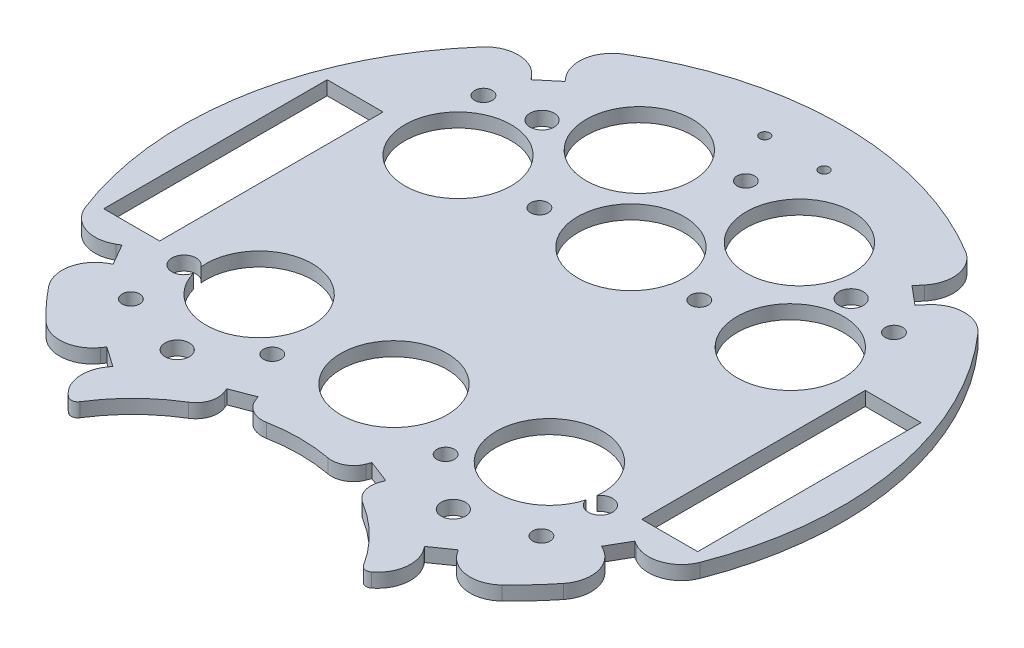
from build123d import *

# Parameters (mm, degrees)
SKETCH1_R           = 2
SKETCH1_R_2         = 2.75
SKETCH1_W           = 12.7
SKETCH1_H           = 50.8
SKETCH1_R_3         = 12.095
SKETCH1_R_4         = 12.075
SKETCH1_R_5         = 1.143
BOSS_EXTRUDE1_DEPTH = 3.175


with BuildPart() as part:
    # Sketch1 → Boss-Extrude1 (new body)
    with BuildSketch(Plane(origin=(0, 0, 0), x_dir=(1, 0, 0), z_dir=(0, 1, 0))):
        with BuildLine():
            Line((-35.441180971, -55.409730648), (-36.014757408, -56.228882693))
            ThreePointArc((-36.014757408, -56.228882693), (-37.282182463, -61.682274385), (-34.419720881, -66.493943628))
            ThreePointArc((-34.419720881, -66.493943628), (-33.243515234, -66.777434912), (-32.240681933, -66.10056535))
            ThreePointArc((-32.240681933, -66.10056535), (-26.728650164, -59.250774979), (-19.793246149, -53.846860332))
            ThreePointArc((-19.793246149, -53.846860332), (-17.659799789, -51.192486841), (-17.721018114, -47.787557426))
            Line((-17.721018114, -47.787557426), (-18.078412971, -46.853604046))
            Line((-18.078412971, -46.853604046), (-12.941669381, -44.887932332))
            Line((-12.941669381, -44.887932332), (-12.584274523, -45.821885712))
            ThreePointArc((-12.584274523, -45.821885712), (-10.356790186, -48.397852623), (-6.996351286, -48.949887413))
            ThreePointArc((-6.996351286, -48.949887413), (0, -48.302004425), (6.996351286, -48.949887413))
            ThreePointArc((6.996351286, -48.949887413), (10.356790186, -48.397852623), (12.584274523, -45.821885712))
            Line((12.584274523, -45.821885712), (12.941669381, -44.887932332))
            Line((12.941669381, -44.887932332), (18.078412971, -46.853604046))
            Line((18.078412971, -46.853604046), (17.721018114, -47.787557426))
            ThreePointArc((17.721018114, -47.787557426), (17.659799789, -51.192486841), (19.793246149, -53.846860332))
            ThreePointArc((19.793246149, -53.846860332), (26.728650164, -59.250774979), (32.240681933, -66.10056535))
            ThreePointArc((32.240681933, -66.10056535), (33.243515234, -66.777434912), (34.419720881, -66.493943628))
            ThreePointArc((34.419720881, -66.493943628), (37.282182463, -61.682274385), (36.014757408, -56.228882693))
            Line((36.014757408, -56.228882693), (35.441180971, -55.409730648))
            Line((35.441180971, -55.409730648), (39.946517215, -52.255060248))
            Line((39.946517215, -52.255060248), (40.520093651, -53.074212293))
            ThreePointArc((40.520093651, -53.074212293), (45.927580176, -56.23617342), (51.848593315, -54.191543356))
            ThreePointArc((51.848593315, -54.191543356), (55.295899374, -50.669157408), (58.504414423, -46.927960674))
            ThreePointArc((58.504414423, -46.927960674), (60.025192689, -40.851285995), (56.403972981, -35.739974078))
            Line((56.403972981, -35.739974078), (55.537947577, -35.239974078))
            Line((55.537947577, -35.239974078), (58.287686569, -30.477286437))
            Line((58.287686569, -30.477286437), (59.153711973, -30.977286437))
            ThreePointArc((59.153711973, -30.977286437), (65.390847794, -31.557698738), (69.893013303, -27.202328787))
            ThreePointArc((69.893013303, -27.202328787), (73.860606951, 13.023468848), (56.374397975, 49.466425512))
            ThreePointArc((56.374397975, 49.466425512), (50.654117331, 52.01932544), (44.991624855, 49.340690033))
            Line((44.991624855, 49.340690033), (43.706049635, 47.808601147))
            Line((43.706049635, 47.808601147), (39.492805198, 51.343933))
            Line((39.492805198, 51.343933), (40.778380417, 52.876021886))
            ThreePointArc((40.778380417, 52.876021886), (42.433039833, 58.917628536), (38.925607882, 64.107698843))
            ThreePointArc((38.925607882, 64.107698843), (0, 75), (-38.925607882, 64.107698843))
            ThreePointArc((-38.925607882, 64.107698843), (-42.433039833, 58.917628536), (-40.778380417, 52.876021886))
            Line((-40.778380417, 52.876021886), (-40.135592808, 52.109977443))
            Line((-40.135592808, 52.109977443), (-44.348837245, 48.57464559))
            Line((-44.348837245, 48.57464559), (-44.991624855, 49.340690033))
            ThreePointArc((-44.991624855, 49.340690033), (-50.654117331, 52.01932544), (-56.374397975, 49.466425512))
            ThreePointArc((-56.374397975, 49.466425512), (-73.860606951, 13.023468848), (-69.893013303, -27.202328787))
            ThreePointArc((-69.893013303, -27.202328787), (-65.390847794, -31.557698738), (-59.153711973, -30.977286437))
            Line((-59.153711973, -30.977286437), (-58.287686569, -30.477286437))
            Line((-58.287686569, -30.477286437), (-55.537947577, -35.239974078))
            Line((-55.537947577, -35.239974078), (-56.403972981, -35.739974078))
            ThreePointArc((-56.403972981, -35.739974078), (-60.025192689, -40.851285995), (-58.504414423, -46.927960674))
            ThreePointArc((-58.504414423, -46.927960674), (-55.295899374, -50.669157408), (-51.848593315, -54.191543356))
            ThreePointArc((-51.848593315, -54.191543356), (-45.927580176, -56.23617342), (-40.520093651, -53.074212293))
            Line((-40.520093651, -53.074212293), (-39.946517215, -52.255060249))
            Line((-39.946517215, -52.255060249), (-35.441180971, -55.409730648))
        make_face()
        with Locations((-46.663733983, -40.081231883)):
            Circle(SKETCH1_R, mode=Mode.SUBTRACT)
        with Locations((-31.384508293, -44.821722961)):
            Circle(SKETCH1_R_2, mode=Mode.SUBTRACT)
        with Locations((-19.709430746, -34.896815973)):
            Circle(SKETCH1_R, mode=Mode.SUBTRACT)
        with Locations((-61.164123727, 0)):
            Rectangle(SKETCH1_W, SKETCH1_H, mode=Mode.SUBTRACT)
        with BuildLine():
            ThreePointArc((-45.027393846, -25.827452847), (-33.613665776, -12.513676165), (-20.900567885, -24.59287233))
            ThreePointArc((-20.900567885, -24.59287233), (-31.339636328, -36.573978943), (-44.637139307, -27.873549061))
            ThreePointArc((-44.637139307, -27.873549061), (-50.033654419, -27.842568285), (-45.027393846, -25.827452847))
        make_face(mode=Mode.SUBTRACT)
        with Locations((31.384508293, -44.821722961)):
            Circle(SKETCH1_R_2, mode=Mode.SUBTRACT)
        with Locations((19.709430746, -34.896815973)):
            Circle(SKETCH1_R, mode=Mode.SUBTRACT)
        with Locations((46.663733983, -40.081231883)):
            Circle(SKETCH1_R, mode=Mode.SUBTRACT)
        with Locations((0, -26.93833729)):
            Circle(SKETCH1_R_3, mode=Mode.SUBTRACT)
        with BuildLine():
            ThreePointArc((44.637139307, -27.873549061), (21.014461272, -22.936940773), (45.090567885, -24.59287233))
            ThreePointArc((45.090567885, -24.59287233), (45.07476405, -25.210970221), (45.027393846, -25.827452847))
            ThreePointArc((45.027393846, -25.827452847), (48.114612939, -24.690952678), (50.082350097, -27.32734507))
            ThreePointArc((50.082350097, -27.32734507), (47.606822617, -30.063613484), (44.637139307, -27.873549061))
        make_face(mode=Mode.SUBTRACT)
        with Locations((61.164123727, 0)):
            Rectangle(SKETCH1_W, SKETCH1_H, mode=Mode.SUBTRACT)
        with Locations((-37.772386795, 25.4)):
            Circle(SKETCH1_R_4, mode=Mode.SUBTRACT)
        with Locations((-18.178952795, 24.310551096)):
            Circle(SKETCH1_R, mode=Mode.SUBTRACT)
        with Locations((-46.663733983, 40.081231883)):
            Circle(SKETCH1_R, mode=Mode.SUBTRACT)
        with Locations((-35.134053633, 41.871134639)):
            Circle(SKETCH1_R_2, mode=Mode.SUBTRACT)
        with Locations((-18.1962694, 47.04580506)):
            Circle(SKETCH1_R_3, mode=Mode.SUBTRACT)
        with Locations((-6.731, 64.107698843)):
            Circle(SKETCH1_R_5, mode=Mode.SUBTRACT)
        with Locations((0, 26.93833729)):
            Circle(SKETCH1_R_3, mode=Mode.SUBTRACT)
        with Locations((18.178952795, 24.310551096)):
            Circle(SKETCH1_R, mode=Mode.SUBTRACT)
        with Locations((37.772386795, 25.4)):
            Circle(SKETCH1_R_3, mode=Mode.SUBTRACT)
        with Locations((18.1962694, 47.04580506)):
            Circle(SKETCH1_R_3, mode=Mode.SUBTRACT)
        with Locations((0, 53.061187965)):
            Circle(SKETCH1_R, mode=Mode.SUBTRACT)
        with Locations((35.134053633, 41.871134639)):
            Circle(SKETCH1_R_2, mode=Mode.SUBTRACT)
        with Locations((6.731, 64.107698843)):
            Circle(SKETCH1_R_5, mode=Mode.SUBTRACT)
        with Locations((46.663733983, 40.081231883)):
            Circle(SKETCH1_R, mode=Mode.SUBTRACT)
    extrude(amount=BOSS_EXTRUDE1_DEPTH)


solid = part.part
